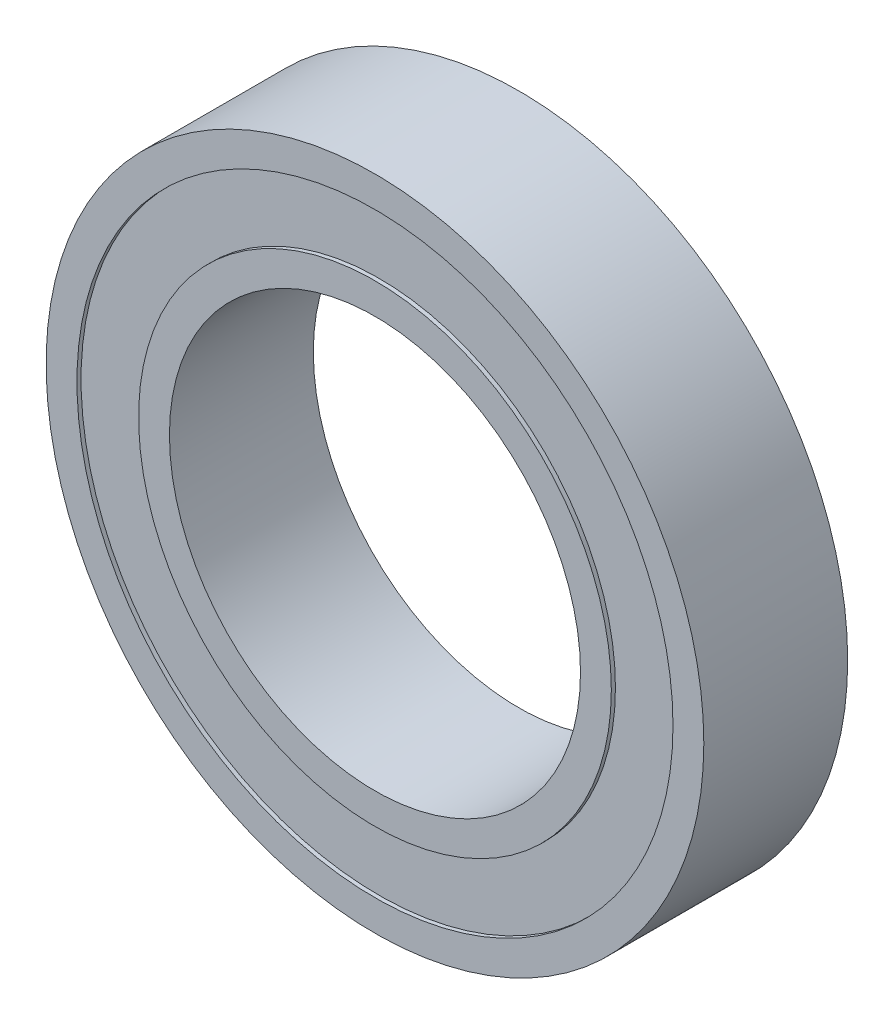
from build123d import *

# Parameters (mm, degrees)
ESQUISSE1_R             = 16
ESQUISSE1_R_2           = 10
BOSS_EXTRU_1_DEPTH      = 7
ESQUISSE2_R             = 14.5
ESQUISSE2_R_2           = 11.5
ENL_V_MAT_EXTRU_1_DEPTH = 0.2
ESQUISSE3_R             = 14.5
ESQUISSE3_R_2           = 11.5
ENL_V_MAT_EXTRU_2_DEPTH = 0.2


with BuildPart() as part:
    # Esquisse1 → Boss.-Extru.1 (new body)
    with BuildSketch(Plane.XY):
        Circle(ESQUISSE1_R)
        Circle(ESQUISSE1_R_2, mode=Mode.SUBTRACT)
    extrude(amount=BOSS_EXTRU_1_DEPTH)

    # Esquisse2 → Enlèv. mat.-Extru.1 (cut)
    with BuildSketch(Plane.XY.offset(7)):
        Circle(ESQUISSE2_R)
        Circle(ESQUISSE2_R_2, mode=Mode.SUBTRACT)
    extrude(amount=-ENL_V_MAT_EXTRU_1_DEPTH, mode=Mode.SUBTRACT)

    # Esquisse3 → Enlèv. mat.-Extru.2 (cut)
    with BuildSketch(Plane(origin=(0, 0, 0), x_dir=(-1, 0, 0), z_dir=(0, 0, -1))):
        Circle(ESQUISSE3_R)
        Circle(ESQUISSE3_R_2, mode=Mode.SUBTRACT)
    extrude(amount=-ENL_V_MAT_EXTRU_2_DEPTH, mode=Mode.SUBTRACT)


solid = part.part
